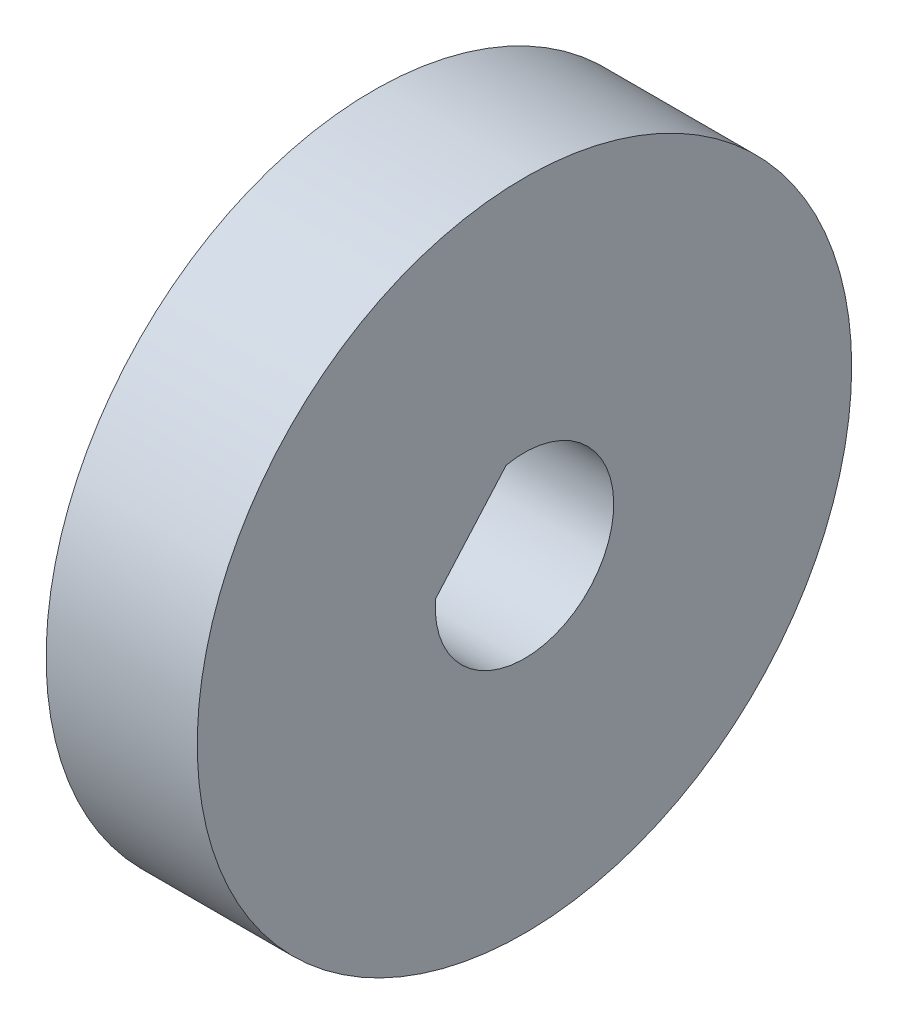
from build123d import *

# Parameters (mm, degrees)
SKETCH1_R           = 11
BOSS_EXTRUDE1_DEPTH = 5.08
CUT_EXTRUDE1_REACH  = 7.08


with BuildPart() as part:
    # Sketch1 → Boss-Extrude1 (new body)
    with BuildSketch(Plane(origin=(0, 0, 0), x_dir=(0, 0, -1), z_dir=(1, 0, 0))):
        Circle(SKETCH1_R)
    extrude(amount=BOSS_EXTRUDE1_DEPTH)

    # Sketch2 → Cut-Extrude1 (cut, up to next)
    with BuildSketch(Plane.ZY, mode=Mode.PRIVATE) as cut_extrude1_sk1:
        with BuildLine():
            Line((0.615357171, 2.936211088), (2.991062652, 0.23139622))
            ThreePointArc((2.991062652, 0.23139622), (-2.25401239, -1.979754567), (0.615357171, 2.936211088))
        make_face()
    cut_extrude1_tool1 = extrude(cut_extrude1_sk1.sketch, amount=-CUT_EXTRUDE1_REACH, mode=Mode.PRIVATE) & part.part
    add(cut_extrude1_tool1.solids().sort_by_distance((0, -0.095727, -0.108989))[0], mode=Mode.SUBTRACT)


solid = part.part
